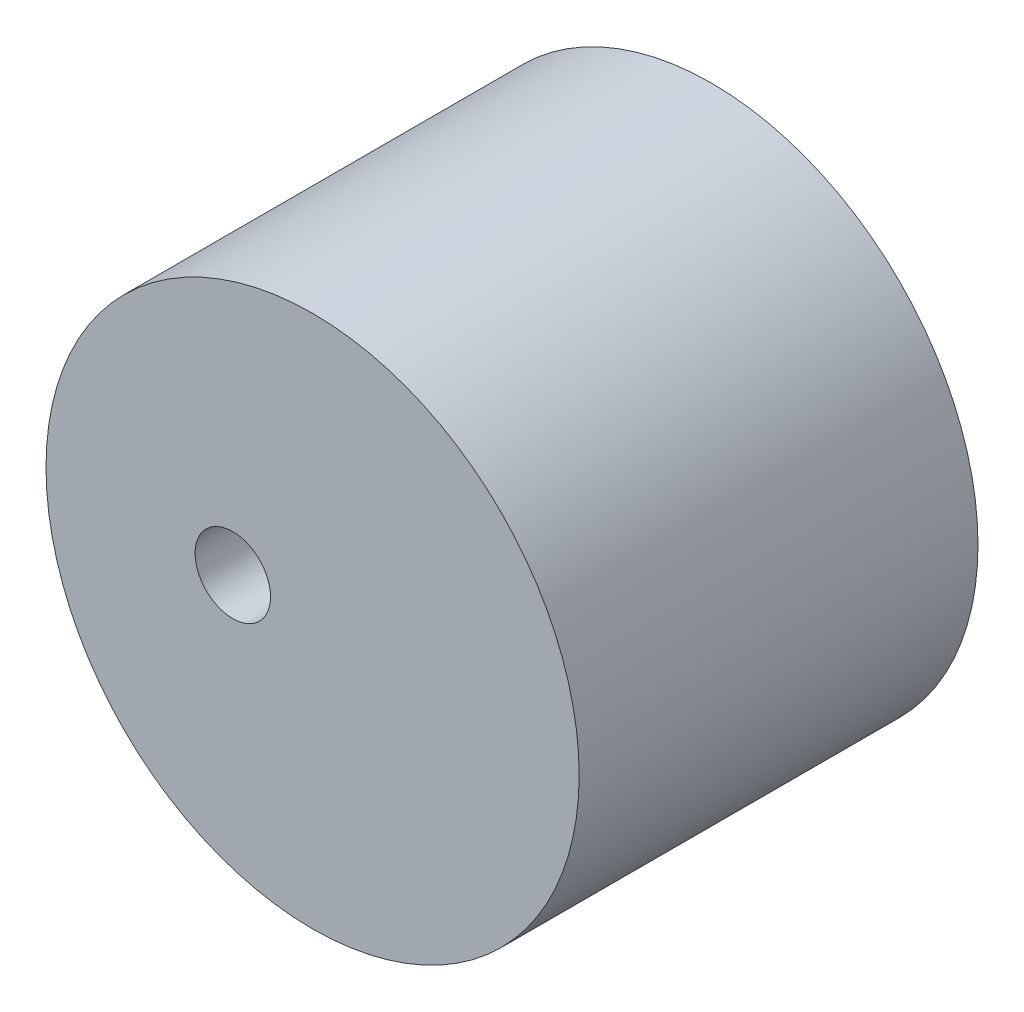
from build123d import *

# Parameters (mm, degrees)
SKETCH11_R           = 23.39375
SKETCH11_R_2         = 3.3085
BOSS_EXTRUDE13_DEPTH = 35


with BuildPart() as part:
    # Sketch11 → Boss-Extrude13 (new body)
    with BuildSketch(Plane.XY):
        Circle(SKETCH11_R)
        with Locations((-7, 0)):
            Circle(SKETCH11_R_2, mode=Mode.SUBTRACT)
    extrude(amount=BOSS_EXTRUDE13_DEPTH)


solid = part.part
